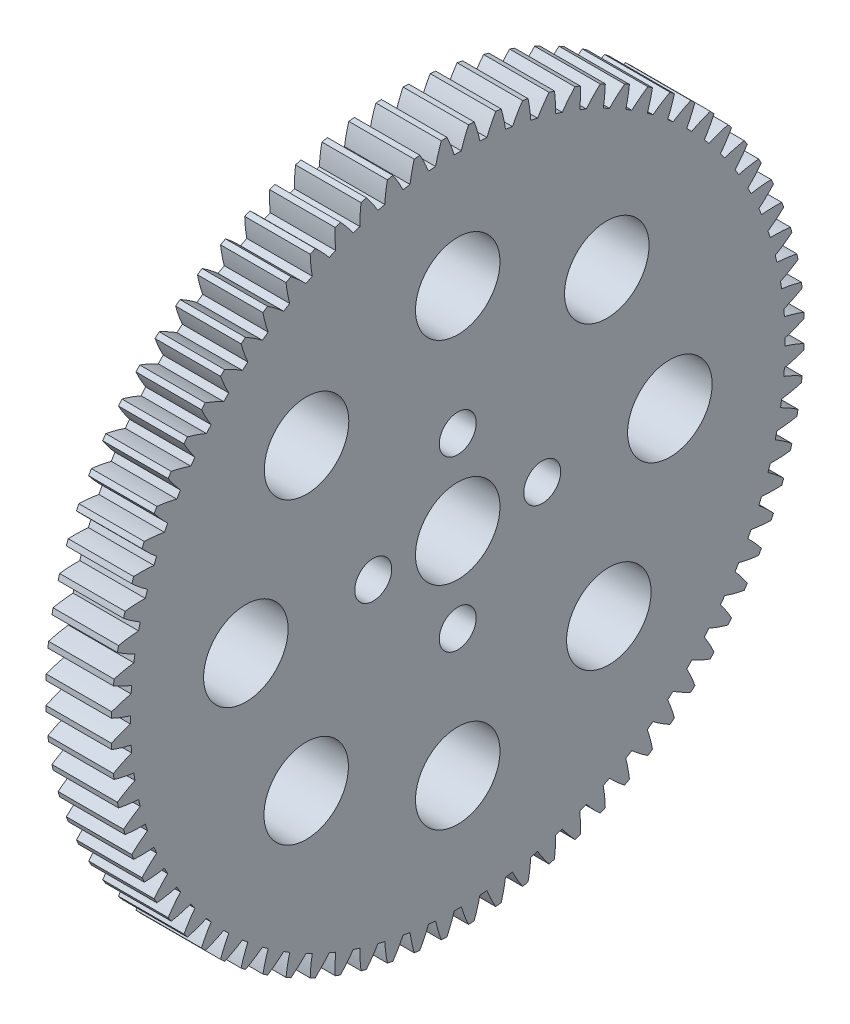
from build123d import *

# Parameters (mm, degrees)
SKETCH1_R           = 4
SKETCH1_R_2         = 1.75
BOSS_EXTRUDE1_DEPTH = 6.2


with BuildPart() as part:
    # Sketch1 → Boss-Extrude1 (new body)
    with BuildSketch(Plane(origin=(0, 0, 0), x_dir=(0, -1, 0), z_dir=(-1, 0, 0))):
        with BuildLine():
            ThreePointArc((-32.540485036, -4.117867604), (-31.611759802, -4.35271874), (-30.668071435, -4.517454533))
            ThreePointArc((-30.668071435, -4.517454533), (-30.61735087, -4.849311982), (-30.563039402, -5.180600688))
            ThreePointArc((-30.563039402, -5.180600688), (-31.409634214, -5.62888948), (-32.220331407, -6.139238063))
            ThreePointArc((-32.220331407, -6.139238063), (-32.169757197, -6.398962562), (-32.117089412, -6.658270623))
            ThreePointArc((-32.117089412, -6.658270623), (-31.17280092, -6.819530849), (-30.219096608, -6.909717881))
            ThreePointArc((-30.219096608, -6.909717881), (-30.142495162, -7.236572834), (-30.062358507, -7.562579059))
            ThreePointArc((-30.062358507, -7.562579059), (-30.871171216, -8.075908989), (-31.639327812, -8.648290907))
            ThreePointArc((-31.639327812, -8.648290907), (-31.568531756, -8.903246756), (-31.495681252, -9.15762319))
            ThreePointArc((-31.495681252, -9.15762319), (-30.541651355, -9.244298283), (-29.583811002, -9.25938052))
            ThreePointArc((-29.583811002, -9.25938052), (-29.481800949, -9.579217809), (-29.376333174, -9.897931615))
            ThreePointArc((-29.376333174, -9.897931615), (-30.142377181, -10.473137835), (-30.863257239, -11.104024162))
            ThreePointArc((-30.863257239, -11.104024162), (-30.772675818, -11.352639472), (-30.680091743, -11.600515964))
            ThreePointArc((-30.680091743, -11.600515964), (-29.722202353, -11.612071544), (-28.766131363, -11.551955999))
            ThreePointArc((-28.766131363, -11.551955999), (-28.639341628, -11.86280372), (-28.509192978, -12.172260132))
            ThreePointArc((-28.509192978, -12.172260132), (-29.227745368, -12.805796303), (-29.896904422, -13.491297415))
            ThreePointArc((-29.896904422, -13.491297415), (-29.787096101, -13.732039391), (-29.675349267, -13.9718877))
            ThreePointArc((-29.675349267, -13.9718877), (-28.719506089, -13.908252522), (-27.771098959, -13.773309829))
            ThreePointArc((-27.771098959, -13.773309829), (-27.620311243, -14.073251501), (-27.466284128, -14.371542617))
            ThreePointArc((-27.466284128, -14.371542617), (-28.132914785, -15.059502778), (-28.746227248, -15.795392334))
            ThreePointArc((-28.746227248, -15.795392334), (-28.617869032, -16.026776721), (-28.487648394, -16.257118102))
            ThreePointArc((-28.487648394, -16.257118102), (-27.53974452, -16.118684499), (-26.604848494, -15.909746623))
            ThreePointArc((-26.604848494, -15.909746623), (-26.430992455, -16.196933008), (-26.254036502, -16.482219763))
            ThreePointArc((-26.254036502, -16.482219763), (-26.864635428, -17.220362411), (-27.418320024, -18.002103406))
            ThreePointArc((-27.418320024, -18.002103406), (-27.272203284, -18.222703643), (-27.124311696, -18.442117965))
            ThreePointArc((-27.124311696, -18.442117965), (-26.190191269, -18.229739426), (-25.274570292, -17.948094538))
            ThreePointArc((-25.274570292, -17.948094538), (-25.078717809, -18.220755036), (-24.879924011, -18.491278544))
            ThreePointArc((-24.879924011, -18.491278544), (-25.430726659, -19.275052784), (-25.921369739, -20.097825525))
            ThreePointArc((-25.921369739, -20.097825525), (-25.758395333, -20.306281537), (-25.593744596, -20.513416038))
            ThreePointArc((-25.593744596, -20.513416038), (-24.679166779, -20.228401947), (-23.788465959, -19.875786483))
            ThreePointArc((-23.788465959, -19.875786483), (-23.571824528, -20.13224005), (-23.352418516, -20.386332443))
            ThreePointArc((-23.352418516, -20.386332443), (-23.840029005, -21.210906046), (-24.26460559, -22.069637866))
            ThreePointArc((-24.26460559, -22.069637866), (-24.085778309, -22.264664453), (-23.905383551, -22.458242079))
            ThreePointArc((-23.905383551, -22.458242079), (-23.015987019, -22.102349643), (-22.155697823, -21.680937594))
            ThreePointArc((-22.155697823, -21.680937594), (-21.91960311, -21.91960311), (-21.680937594, -22.155697823))
            ThreePointArc((-21.680937594, -22.155697823), (-22.102349643, -23.015987019), (-22.458242079, -23.905383551))
            ThreePointArc((-22.458242079, -23.905383551), (-22.264664453, -24.085778309), (-22.069637866, -24.26460559))
            ThreePointArc((-22.069637866, -24.26460559), (-21.210906046, -23.840029005), (-20.386332443, -23.352418516))
            ThreePointArc((-20.386332443, -23.352418516), (-20.13224005, -23.571824528), (-19.875786483, -23.788465959))
            ThreePointArc((-19.875786483, -23.788465959), (-20.228401947, -24.679166779), (-20.513416038, -25.593744596))
            ThreePointArc((-20.513416038, -25.593744596), (-20.306281537, -25.758395333), (-20.097825525, -25.921369739))
            ThreePointArc((-20.097825525, -25.921369739), (-19.275052784, -25.430726659), (-18.491278544, -24.879924011))
            ThreePointArc((-18.491278544, -24.879924011), (-18.220755036, -25.078717809), (-17.948094538, -25.274570292))
            ThreePointArc((-17.948094538, -25.274570292), (-18.229739426, -26.190191269), (-18.442117965, -27.124311696))
            ThreePointArc((-18.442117965, -27.124311696), (-18.222703643, -27.272203284), (-18.002103406, -27.418320024))
            ThreePointArc((-18.002103406, -27.418320024), (-17.220362411, -26.864635428), (-16.482219763, -26.254036502))
            ThreePointArc((-16.482219763, -26.254036502), (-16.196933008, -26.430992455), (-15.909746623, -26.604848494))
            ThreePointArc((-15.909746623, -26.604848494), (-16.118684499, -27.53974452), (-16.257118102, -28.487648394))
            ThreePointArc((-16.257118102, -28.487648394), (-16.026776721, -28.617869032), (-15.795392334, -28.746227248))
            ThreePointArc((-15.795392334, -28.746227248), (-15.059502778, -28.132914785), (-14.371542617, -27.466284128))
            ThreePointArc((-14.371542617, -27.466284128), (-14.073251501, -27.620311243), (-13.773309829, -27.771098959))
            ThreePointArc((-13.773309829, -27.771098959), (-13.908252522, -28.719506089), (-13.9718877, -29.675349267))
            ThreePointArc((-13.9718877, -29.675349267), (-13.732039391, -29.787096101), (-13.491297415, -29.896904422))
            ThreePointArc((-13.491297415, -29.896904422), (-12.805796303, -29.227745368), (-12.172260132, -28.509192978))
            ThreePointArc((-12.172260132, -28.509192978), (-11.86280372, -28.639341628), (-11.551955999, -28.766131363))
            ThreePointArc((-11.551955999, -28.766131363), (-11.612071544, -29.722202353), (-11.600515964, -30.680091743))
            ThreePointArc((-11.600515964, -30.680091743), (-11.352639472, -30.772675818), (-11.104024162, -30.863257239))
            ThreePointArc((-11.104024162, -30.863257239), (-10.473137835, -30.142377181), (-9.897931615, -29.376333174))
            ThreePointArc((-9.897931615, -29.376333174), (-9.579217809, -29.481800949), (-9.25938052, -29.583811002))
            ThreePointArc((-9.25938052, -29.583811002), (-9.244298283, -30.541651355), (-9.15762319, -31.495681252))
            ThreePointArc((-9.15762319, -31.495681252), (-8.903246756, -31.568531756), (-8.648290907, -31.639327812))
            ThreePointArc((-8.648290907, -31.639327812), (-8.075908989, -30.871171216), (-7.562579059, -30.062358507))
            ThreePointArc((-7.562579059, -30.062358507), (-7.236572834, -30.142495162), (-6.909717881, -30.219096608))
            ThreePointArc((-6.909717881, -30.219096608), (-6.819530849, -31.17280092), (-6.658270623, -32.117089412))
            ThreePointArc((-6.658270623, -32.117089412), (-6.398962562, -32.169757197), (-6.139238063, -32.220331407))
            ThreePointArc((-6.139238063, -32.220331407), (-5.62888948, -31.409634214), (-5.180600688, -30.563039402))
            ThreePointArc((-5.180600688, -30.563039402), (-4.849311982, -30.61735087), (-4.517454533, -30.668071435))
            ThreePointArc((-4.517454533, -30.668071435), (-4.35271874, -31.611759802), (-4.117867604, -32.540485036))
            ThreePointArc((-4.117867604, -32.540485036), (-3.855226637, -32.572645388), (-3.592334775, -32.602685946))
            ThreePointArc((-3.592334775, -32.602685946), (-3.147165994, -31.754446373), (-2.76668219, -30.875288997))
            ThreePointArc((-2.76668219, -30.875288997), (-2.432153508, -30.903440428), (-2.097339576, -30.927967403))
            ThreePointArc((-2.097339576, -30.927967403), (-1.859070673, -31.855821673), (-1.552076562, -32.763257749))
            ThreePointArc((-1.552076562, -32.763257749), (-1.287721957, -32.774712389), (-1.023283548, -32.784034083))
            ThreePointArc((-1.023283548, -32.784034083), (-0.646039184, -31.90348181), (-0.335706178, -30.997182168))
            ThreePointArc((-0.335706178, -30.997182168), (0, -30.999), (0.335706178, -30.997182168))
            ThreePointArc((0.335706178, -30.997182168), (0.646039184, -31.90348181), (1.023283548, -32.784034083))
            ThreePointArc((1.023283548, -32.784034083), (1.287721957, -32.774712389), (1.552076562, -32.763257749))
            ThreePointArc((1.552076562, -32.763257749), (1.859070673, -31.855821673), (2.097339576, -30.927967403))
            ThreePointArc((2.097339576, -30.927967403), (2.432153508, -30.903440428), (2.76668219, -30.875288997))
            ThreePointArc((2.76668219, -30.875288997), (3.147165994, -31.754446373), (3.592334775, -32.602685946))
            ThreePointArc((3.592334775, -32.602685946), (3.855226637, -32.572645388), (4.117867604, -32.540485036))
            ThreePointArc((4.117867604, -32.540485036), (4.35271874, -31.611759802), (4.517454533, -30.668071435))
            ThreePointArc((4.517454533, -30.668071435), (4.849311982, -30.61735087), (5.180600688, -30.563039402))
            ThreePointArc((5.180600688, -30.563039402), (5.62888948, -31.409634214), (6.139238063, -32.220331407))
            ThreePointArc((6.139238063, -32.220331407), (6.398962562, -32.169757197), (6.658270623, -32.117089412))
            ThreePointArc((6.658270623, -32.117089412), (6.819530849, -31.17280092), (6.909717881, -30.219096608))
            ThreePointArc((6.909717881, -30.219096608), (7.236572834, -30.142495162), (7.562579059, -30.062358507))
            ThreePointArc((7.562579059, -30.062358507), (8.075908989, -30.871171216), (8.648290907, -31.639327812))
            ThreePointArc((8.648290907, -31.639327812), (8.903246756, -31.568531756), (9.15762319, -31.495681252))
            ThreePointArc((9.15762319, -31.495681252), (9.244298283, -30.541651355), (9.25938052, -29.583811002))
            ThreePointArc((9.25938052, -29.583811002), (9.579217809, -29.481800949), (9.897931615, -29.376333174))
            ThreePointArc((9.897931615, -29.376333174), (10.473137835, -30.142377181), (11.104024162, -30.863257239))
            ThreePointArc((11.104024162, -30.863257239), (11.352639472, -30.772675818), (11.600515964, -30.680091743))
            ThreePointArc((11.600515964, -30.680091743), (11.612071544, -29.722202353), (11.551955999, -28.766131363))
            ThreePointArc((11.551955999, -28.766131363), (11.86280372, -28.639341628), (12.172260132, -28.509192978))
            ThreePointArc((12.172260132, -28.509192978), (12.805796303, -29.227745368), (13.491297415, -29.896904422))
            ThreePointArc((13.491297415, -29.896904422), (13.732039391, -29.787096101), (13.9718877, -29.675349267))
            ThreePointArc((13.9718877, -29.675349267), (13.908252522, -28.719506089), (13.773309829, -27.771098959))
            ThreePointArc((13.773309829, -27.771098959), (14.073251501, -27.620311243), (14.371542617, -27.466284128))
            ThreePointArc((14.371542617, -27.466284128), (15.059502778, -28.132914785), (15.795392334, -28.746227248))
            ThreePointArc((15.795392334, -28.746227248), (16.026776721, -28.617869032), (16.257118102, -28.487648394))
            ThreePointArc((16.257118102, -28.487648394), (16.118684499, -27.53974452), (15.909746623, -26.604848494))
            ThreePointArc((15.909746623, -26.604848494), (16.196933008, -26.430992455), (16.482219763, -26.254036502))
            ThreePointArc((16.482219763, -26.254036502), (17.220362411, -26.864635428), (18.002103406, -27.418320024))
            ThreePointArc((18.002103406, -27.418320024), (18.222703643, -27.272203284), (18.442117965, -27.124311696))
            ThreePointArc((18.442117965, -27.124311696), (18.229739426, -26.190191269), (17.948094538, -25.274570292))
            ThreePointArc((17.948094538, -25.274570292), (18.220755036, -25.078717809), (18.491278544, -24.879924011))
            ThreePointArc((18.491278544, -24.879924011), (19.275052784, -25.430726659), (20.097825525, -25.921369739))
            ThreePointArc((20.097825525, -25.921369739), (20.306281537, -25.758395333), (20.513416038, -25.593744596))
            ThreePointArc((20.513416038, -25.593744596), (20.228401947, -24.679166779), (19.875786483, -23.788465959))
            ThreePointArc((19.875786483, -23.788465959), (20.13224005, -23.571824528), (20.386332443, -23.352418516))
            ThreePointArc((20.386332443, -23.352418516), (21.210906046, -23.840029005), (22.069637866, -24.26460559))
            ThreePointArc((22.069637866, -24.26460559), (22.264664453, -24.085778309), (22.458242079, -23.905383551))
            ThreePointArc((22.458242079, -23.905383551), (22.102349643, -23.015987019), (21.680937594, -22.155697823))
            ThreePointArc((21.680937594, -22.155697823), (21.91960311, -21.91960311), (22.155697823, -21.680937594))
            ThreePointArc((22.155697823, -21.680937594), (23.015987019, -22.102349643), (23.905383551, -22.458242079))
            ThreePointArc((23.905383551, -22.458242079), (24.085778309, -22.264664453), (24.26460559, -22.069637866))
            ThreePointArc((24.26460559, -22.069637866), (23.840029005, -21.210906046), (23.352418516, -20.386332443))
            ThreePointArc((23.352418516, -20.386332443), (23.571824528, -20.13224005), (23.788465959, -19.875786483))
            ThreePointArc((23.788465959, -19.875786483), (24.679166779, -20.228401947), (25.593744596, -20.513416038))
            ThreePointArc((25.593744596, -20.513416038), (25.758395333, -20.306281537), (25.921369739, -20.097825525))
            ThreePointArc((25.921369739, -20.097825525), (25.430726659, -19.275052784), (24.879924011, -18.491278544))
            ThreePointArc((24.879924011, -18.491278544), (25.078717809, -18.220755036), (25.274570292, -17.948094538))
            ThreePointArc((25.274570292, -17.948094538), (26.190191269, -18.229739426), (27.124311696, -18.442117965))
            ThreePointArc((27.124311696, -18.442117965), (27.272203284, -18.222703643), (27.418320024, -18.002103406))
            ThreePointArc((27.418320024, -18.002103406), (26.864635428, -17.220362411), (26.254036502, -16.482219763))
            ThreePointArc((26.254036502, -16.482219763), (26.430992455, -16.196933008), (26.604848494, -15.909746623))
            ThreePointArc((26.604848494, -15.909746623), (27.53974452, -16.118684499), (28.487648394, -16.257118102))
            ThreePointArc((28.487648394, -16.257118102), (28.617869032, -16.026776721), (28.746227248, -15.795392334))
            ThreePointArc((28.746227248, -15.795392334), (28.132914785, -15.059502778), (27.466284128, -14.371542617))
            ThreePointArc((27.466284128, -14.371542617), (27.620311243, -14.073251501), (27.771098959, -13.773309829))
            ThreePointArc((27.771098959, -13.773309829), (28.719506089, -13.908252522), (29.675349267, -13.9718877))
            ThreePointArc((29.675349267, -13.9718877), (29.787096101, -13.732039391), (29.896904422, -13.491297415))
            ThreePointArc((29.896904422, -13.491297415), (29.227745368, -12.805796303), (28.509192978, -12.172260132))
            ThreePointArc((28.509192978, -12.172260132), (28.639341628, -11.86280372), (28.766131363, -11.551955999))
            ThreePointArc((28.766131363, -11.551955999), (29.722202353, -11.612071544), (30.680091743, -11.600515964))
            ThreePointArc((30.680091743, -11.600515964), (30.772675818, -11.352639472), (30.863257239, -11.104024162))
            ThreePointArc((30.863257239, -11.104024162), (30.142377181, -10.473137835), (29.376333174, -9.897931615))
            ThreePointArc((29.376333174, -9.897931615), (29.481800949, -9.579217809), (29.583811002, -9.25938052))
            ThreePointArc((29.583811002, -9.25938052), (30.541651355, -9.244298283), (31.495681252, -9.15762319))
            ThreePointArc((31.495681252, -9.15762319), (31.568531756, -8.903246756), (31.639327812, -8.648290907))
            ThreePointArc((31.639327812, -8.648290907), (30.871171216, -8.075908989), (30.062358507, -7.562579059))
            ThreePointArc((30.062358507, -7.562579059), (30.142495162, -7.236572834), (30.219096608, -6.909717881))
            ThreePointArc((30.219096608, -6.909717881), (31.17280092, -6.819530849), (32.117089412, -6.658270623))
            ThreePointArc((32.117089412, -6.658270623), (32.169757197, -6.398962562), (32.220331407, -6.139238063))
            ThreePointArc((32.220331407, -6.139238063), (31.409634214, -5.62888948), (30.563039402, -5.180600688))
            ThreePointArc((30.563039402, -5.180600688), (30.61735087, -4.849311982), (30.668071435, -4.517454533))
            ThreePointArc((30.668071435, -4.517454533), (31.611759802, -4.35271874), (32.540485036, -4.117867604))
            ThreePointArc((32.540485036, -4.117867604), (32.572645388, -3.855226637), (32.602685946, -3.592334775))
            ThreePointArc((32.602685946, -3.592334775), (31.754446373, -3.147165994), (30.875288997, -2.76668219))
            ThreePointArc((30.875288997, -2.76668219), (30.903440428, -2.432153508), (30.927967403, -2.097339576))
            ThreePointArc((30.927967403, -2.097339576), (31.855821673, -1.859070673), (32.763257749, -1.552076562))
            ThreePointArc((32.763257749, -1.552076562), (32.774712389, -1.287721957), (32.784034083, -1.023283548))
            ThreePointArc((32.784034083, -1.023283548), (31.90348181, -0.646039184), (30.997182168, -0.335706178))
            ThreePointArc((30.997182168, -0.335706178), (30.999, 0), (30.997182168, 0.335706178))
            ThreePointArc((30.997182168, 0.335706178), (31.90348181, 0.646039184), (32.784034083, 1.023283548))
            ThreePointArc((32.784034083, 1.023283548), (32.774712389, 1.287721957), (32.763257749, 1.552076562))
            ThreePointArc((32.763257749, 1.552076562), (31.855821673, 1.859070673), (30.927967403, 2.097339576))
            ThreePointArc((30.927967403, 2.097339576), (30.903440428, 2.432153508), (30.875288997, 2.76668219))
            ThreePointArc((30.875288997, 2.76668219), (31.754446373, 3.147165994), (32.602685946, 3.592334775))
            ThreePointArc((32.602685946, 3.592334775), (32.572645388, 3.855226637), (32.540485036, 4.117867604))
            ThreePointArc((32.540485036, 4.117867604), (31.611759802, 4.35271874), (30.668071435, 4.517454533))
            ThreePointArc((30.668071435, 4.517454533), (30.61735087, 4.849311982), (30.563039402, 5.180600688))
            ThreePointArc((30.563039402, 5.180600688), (31.409634214, 5.62888948), (32.220331407, 6.139238063))
            ThreePointArc((32.220331407, 6.139238063), (32.169757197, 6.398962562), (32.117089412, 6.658270623))
            ThreePointArc((32.117089412, 6.658270623), (31.17280092, 6.819530849), (30.219096608, 6.909717881))
            ThreePointArc((30.219096608, 6.909717881), (30.142495162, 7.236572834), (30.062358507, 7.562579059))
            ThreePointArc((30.062358507, 7.562579059), (30.871171216, 8.075908989), (31.639327812, 8.648290907))
            ThreePointArc((31.639327812, 8.648290907), (31.568531756, 8.903246756), (31.495681252, 9.15762319))
            ThreePointArc((31.495681252, 9.15762319), (30.541651355, 9.244298283), (29.583811002, 9.25938052))
            ThreePointArc((29.583811002, 9.25938052), (29.481800949, 9.579217809), (29.376333174, 9.897931615))
            ThreePointArc((29.376333174, 9.897931615), (30.142377181, 10.473137835), (30.863257239, 11.104024162))
            ThreePointArc((30.863257239, 11.104024162), (30.772675818, 11.352639472), (30.680091743, 11.600515964))
            ThreePointArc((30.680091743, 11.600515964), (29.722202353, 11.612071544), (28.766131363, 11.551955999))
            ThreePointArc((28.766131363, 11.551955999), (28.639341628, 11.86280372), (28.509192978, 12.172260132))
            ThreePointArc((28.509192978, 12.172260132), (29.227745368, 12.805796303), (29.896904422, 13.491297415))
            ThreePointArc((29.896904422, 13.491297415), (29.787096101, 13.732039391), (29.675349267, 13.9718877))
            ThreePointArc((29.675349267, 13.9718877), (28.719506089, 13.908252522), (27.771098959, 13.773309829))
            ThreePointArc((27.771098959, 13.773309829), (27.620311243, 14.073251501), (27.466284128, 14.371542617))
            ThreePointArc((27.466284128, 14.371542617), (28.132914785, 15.059502778), (28.746227248, 15.795392334))
            ThreePointArc((28.746227248, 15.795392334), (28.617869032, 16.026776721), (28.487648394, 16.257118102))
            ThreePointArc((28.487648394, 16.257118102), (27.53974452, 16.118684499), (26.604848494, 15.909746623))
            ThreePointArc((26.604848494, 15.909746623), (26.430992455, 16.196933008), (26.254036502, 16.482219763))
            ThreePointArc((26.254036502, 16.482219763), (26.864635428, 17.220362411), (27.418320024, 18.002103406))
            ThreePointArc((27.418320024, 18.002103406), (27.272203284, 18.222703643), (27.124311696, 18.442117965))
            ThreePointArc((27.124311696, 18.442117965), (26.190191269, 18.229739426), (25.274570292, 17.948094538))
            ThreePointArc((25.274570292, 17.948094538), (25.078717809, 18.220755036), (24.879924011, 18.491278544))
            ThreePointArc((24.879924011, 18.491278544), (25.430726659, 19.275052784), (25.921369739, 20.097825525))
            ThreePointArc((25.921369739, 20.097825525), (25.758395333, 20.306281537), (25.593744596, 20.513416038))
            ThreePointArc((25.593744596, 20.513416038), (24.679166779, 20.228401947), (23.788465959, 19.875786483))
            ThreePointArc((23.788465959, 19.875786483), (23.571824528, 20.13224005), (23.352418516, 20.386332443))
            ThreePointArc((23.352418516, 20.386332443), (23.840029005, 21.210906046), (24.26460559, 22.069637866))
            ThreePointArc((24.26460559, 22.069637866), (24.085778309, 22.264664453), (23.905383551, 22.458242079))
            ThreePointArc((23.905383551, 22.458242079), (23.015987019, 22.102349643), (22.155697823, 21.680937594))
            ThreePointArc((22.155697823, 21.680937594), (21.91960311, 21.91960311), (21.680937594, 22.155697823))
            ThreePointArc((21.680937594, 22.155697823), (22.102349643, 23.015987019), (22.458242079, 23.905383551))
            ThreePointArc((22.458242079, 23.905383551), (22.264664453, 24.085778309), (22.069637866, 24.26460559))
            ThreePointArc((22.069637866, 24.26460559), (21.210906046, 23.840029005), (20.386332443, 23.352418516))
            ThreePointArc((20.386332443, 23.352418516), (20.13224005, 23.571824528), (19.875786483, 23.788465959))
            ThreePointArc((19.875786483, 23.788465959), (20.228401947, 24.679166779), (20.513416038, 25.593744596))
            ThreePointArc((20.513416038, 25.593744596), (20.306281537, 25.758395333), (20.097825525, 25.921369739))
            ThreePointArc((20.097825525, 25.921369739), (19.275052784, 25.430726659), (18.491278544, 24.879924011))
            ThreePointArc((18.491278544, 24.879924011), (18.220755036, 25.078717809), (17.948094538, 25.274570292))
            ThreePointArc((17.948094538, 25.274570292), (18.229739426, 26.190191269), (18.442117965, 27.124311696))
            ThreePointArc((18.442117965, 27.124311696), (18.222703643, 27.272203284), (18.002103406, 27.418320024))
            ThreePointArc((18.002103406, 27.418320024), (17.220362411, 26.864635428), (16.482219763, 26.254036502))
            ThreePointArc((16.482219763, 26.254036502), (16.196933008, 26.430992455), (15.909746623, 26.604848494))
            ThreePointArc((15.909746623, 26.604848494), (16.118684499, 27.53974452), (16.257118102, 28.487648394))
            ThreePointArc((16.257118102, 28.487648394), (16.026776721, 28.617869032), (15.795392334, 28.746227248))
            ThreePointArc((15.795392334, 28.746227248), (15.059502778, 28.132914785), (14.371542617, 27.466284128))
            ThreePointArc((14.371542617, 27.466284128), (14.073251501, 27.620311243), (13.773309829, 27.771098959))
            ThreePointArc((13.773309829, 27.771098959), (13.908252522, 28.719506089), (13.9718877, 29.675349267))
            ThreePointArc((13.9718877, 29.675349267), (13.732039391, 29.787096101), (13.491297415, 29.896904422))
            ThreePointArc((13.491297415, 29.896904422), (12.805796303, 29.227745368), (12.172260132, 28.509192978))
            ThreePointArc((12.172260132, 28.509192978), (11.86280372, 28.639341628), (11.551955999, 28.766131363))
            ThreePointArc((11.551955999, 28.766131363), (11.612071544, 29.722202353), (11.600515964, 30.680091743))
            ThreePointArc((11.600515964, 30.680091743), (11.352639472, 30.772675818), (11.104024162, 30.863257239))
            ThreePointArc((11.104024162, 30.863257239), (10.473137835, 30.142377181), (9.897931615, 29.376333174))
            ThreePointArc((9.897931615, 29.376333174), (9.579217809, 29.481800949), (9.25938052, 29.583811002))
            ThreePointArc((9.25938052, 29.583811002), (9.244298283, 30.541651355), (9.15762319, 31.495681252))
            ThreePointArc((9.15762319, 31.495681252), (8.903246756, 31.568531756), (8.648290907, 31.639327812))
            ThreePointArc((8.648290907, 31.639327812), (8.075908989, 30.871171216), (7.562579059, 30.062358507))
            ThreePointArc((7.562579059, 30.062358507), (7.236572834, 30.142495162), (6.909717881, 30.219096608))
            ThreePointArc((6.909717881, 30.219096608), (6.819530849, 31.17280092), (6.658270623, 32.117089412))
            ThreePointArc((6.658270623, 32.117089412), (6.398962562, 32.169757197), (6.139238063, 32.220331407))
            ThreePointArc((6.139238063, 32.220331407), (5.62888948, 31.409634214), (5.180600688, 30.563039402))
            ThreePointArc((5.180600688, 30.563039402), (4.849311982, 30.61735087), (4.517454533, 30.668071435))
            ThreePointArc((4.517454533, 30.668071435), (4.35271874, 31.611759802), (4.117867604, 32.540485036))
            ThreePointArc((4.117867604, 32.540485036), (3.855226637, 32.572645388), (3.592334775, 32.602685946))
            ThreePointArc((3.592334775, 32.602685946), (3.147165994, 31.754446373), (2.76668219, 30.875288997))
            ThreePointArc((2.76668219, 30.875288997), (2.432153508, 30.903440428), (2.097339576, 30.927967403))
            ThreePointArc((2.097339576, 30.927967403), (1.859070673, 31.855821673), (1.552076562, 32.763257749))
            ThreePointArc((1.552076562, 32.763257749), (1.287721957, 32.774712389), (1.023283548, 32.784034083))
            ThreePointArc((1.023283548, 32.784034083), (0.646039184, 31.90348181), (0.335706178, 30.997182168))
            ThreePointArc((0.335706178, 30.997182168), (0, 30.999), (-0.335706178, 30.997182168))
            ThreePointArc((-0.335706178, 30.997182168), (-0.646039184, 31.90348181), (-1.023283548, 32.784034083))
            ThreePointArc((-1.023283548, 32.784034083), (-1.287721957, 32.774712389), (-1.552076562, 32.763257749))
            ThreePointArc((-1.552076562, 32.763257749), (-1.859070673, 31.855821673), (-2.097339576, 30.927967403))
            ThreePointArc((-2.097339576, 30.927967403), (-2.432153508, 30.903440428), (-2.76668219, 30.875288997))
            ThreePointArc((-2.76668219, 30.875288997), (-3.147165994, 31.754446373), (-3.592334775, 32.602685946))
            ThreePointArc((-3.592334775, 32.602685946), (-3.855226637, 32.572645388), (-4.117867604, 32.540485036))
            ThreePointArc((-4.117867604, 32.540485036), (-4.35271874, 31.611759802), (-4.517454533, 30.668071435))
            ThreePointArc((-4.517454533, 30.668071435), (-4.849311982, 30.61735087), (-5.180600688, 30.563039402))
            ThreePointArc((-5.180600688, 30.563039402), (-5.62888948, 31.409634214), (-6.139238063, 32.220331407))
            ThreePointArc((-6.139238063, 32.220331407), (-6.398962562, 32.169757197), (-6.658270623, 32.117089412))
            ThreePointArc((-6.658270623, 32.117089412), (-6.819530849, 31.17280092), (-6.909717881, 30.219096608))
            ThreePointArc((-6.909717881, 30.219096608), (-7.236572834, 30.142495162), (-7.562579059, 30.062358507))
            ThreePointArc((-7.562579059, 30.062358507), (-8.075908989, 30.871171216), (-8.648290907, 31.639327812))
            ThreePointArc((-8.648290907, 31.639327812), (-8.903246756, 31.568531756), (-9.15762319, 31.495681252))
            ThreePointArc((-9.15762319, 31.495681252), (-9.244298283, 30.541651355), (-9.25938052, 29.583811002))
            ThreePointArc((-9.25938052, 29.583811002), (-9.579217809, 29.481800949), (-9.897931615, 29.376333174))
            ThreePointArc((-9.897931615, 29.376333174), (-10.473137835, 30.142377181), (-11.104024162, 30.863257239))
            ThreePointArc((-11.104024162, 30.863257239), (-11.352639472, 30.772675818), (-11.600515964, 30.680091743))
            ThreePointArc((-11.600515964, 30.680091743), (-11.612071544, 29.722202353), (-11.551955999, 28.766131363))
            ThreePointArc((-11.551955999, 28.766131363), (-11.86280372, 28.639341628), (-12.172260132, 28.509192978))
            ThreePointArc((-12.172260132, 28.509192978), (-12.805796303, 29.227745368), (-13.491297415, 29.896904422))
            ThreePointArc((-13.491297415, 29.896904422), (-13.732039391, 29.787096101), (-13.9718877, 29.675349267))
            ThreePointArc((-13.9718877, 29.675349267), (-13.908252522, 28.719506089), (-13.773309829, 27.771098959))
            ThreePointArc((-13.773309829, 27.771098959), (-14.073251501, 27.620311243), (-14.371542617, 27.466284128))
            ThreePointArc((-14.371542617, 27.466284128), (-15.059502778, 28.132914785), (-15.795392334, 28.746227248))
            ThreePointArc((-15.795392334, 28.746227248), (-16.026776721, 28.617869032), (-16.257118102, 28.487648394))
            ThreePointArc((-16.257118102, 28.487648394), (-16.118684499, 27.53974452), (-15.909746623, 26.604848494))
            ThreePointArc((-15.909746623, 26.604848494), (-16.196933008, 26.430992455), (-16.482219763, 26.254036502))
            ThreePointArc((-16.482219763, 26.254036502), (-17.220362411, 26.864635428), (-18.002103406, 27.418320024))
            ThreePointArc((-18.002103406, 27.418320024), (-18.222703643, 27.272203284), (-18.442117965, 27.124311696))
            ThreePointArc((-18.442117965, 27.124311696), (-18.229739426, 26.190191269), (-17.948094538, 25.274570292))
            ThreePointArc((-17.948094538, 25.274570292), (-18.220755036, 25.078717809), (-18.491278544, 24.879924011))
            ThreePointArc((-18.491278544, 24.879924011), (-19.275052784, 25.430726659), (-20.097825525, 25.921369739))
            ThreePointArc((-20.097825525, 25.921369739), (-20.306281537, 25.758395333), (-20.513416038, 25.593744596))
            ThreePointArc((-20.513416038, 25.593744596), (-20.228401947, 24.679166779), (-19.875786483, 23.788465959))
            ThreePointArc((-19.875786483, 23.788465959), (-20.13224005, 23.571824528), (-20.386332443, 23.352418516))
            ThreePointArc((-20.386332443, 23.352418516), (-21.210906046, 23.840029005), (-22.069637866, 24.26460559))
            ThreePointArc((-22.069637866, 24.26460559), (-22.264664453, 24.085778309), (-22.458242079, 23.905383551))
            ThreePointArc((-22.458242079, 23.905383551), (-22.102349643, 23.015987019), (-21.680937594, 22.155697823))
            ThreePointArc((-21.680937594, 22.155697823), (-21.91960311, 21.91960311), (-22.155697823, 21.680937594))
            ThreePointArc((-22.155697823, 21.680937594), (-23.015987019, 22.102349643), (-23.905383551, 22.458242079))
            ThreePointArc((-23.905383551, 22.458242079), (-24.085778309, 22.264664453), (-24.26460559, 22.069637866))
            ThreePointArc((-24.26460559, 22.069637866), (-23.840029005, 21.210906046), (-23.352418516, 20.386332443))
            ThreePointArc((-23.352418516, 20.386332443), (-23.571824528, 20.13224005), (-23.788465959, 19.875786483))
            ThreePointArc((-23.788465959, 19.875786483), (-24.679166779, 20.228401947), (-25.593744596, 20.513416038))
            ThreePointArc((-25.593744596, 20.513416038), (-25.758395333, 20.306281537), (-25.921369739, 20.097825525))
            ThreePointArc((-25.921369739, 20.097825525), (-25.430726659, 19.275052784), (-24.879924011, 18.491278544))
            ThreePointArc((-24.879924011, 18.491278544), (-25.078717809, 18.220755036), (-25.274570292, 17.948094538))
            ThreePointArc((-25.274570292, 17.948094538), (-26.190191269, 18.229739426), (-27.124311696, 18.442117965))
            ThreePointArc((-27.124311696, 18.442117965), (-27.272203284, 18.222703643), (-27.418320024, 18.002103406))
            ThreePointArc((-27.418320024, 18.002103406), (-26.864635428, 17.220362411), (-26.254036502, 16.482219763))
            ThreePointArc((-26.254036502, 16.482219763), (-26.430992455, 16.196933008), (-26.604848494, 15.909746623))
            ThreePointArc((-26.604848494, 15.909746623), (-27.53974452, 16.118684499), (-28.487648394, 16.257118102))
            ThreePointArc((-28.487648394, 16.257118102), (-28.617869032, 16.026776721), (-28.746227248, 15.795392334))
            ThreePointArc((-28.746227248, 15.795392334), (-28.132914785, 15.059502778), (-27.466284128, 14.371542617))
            ThreePointArc((-27.466284128, 14.371542617), (-27.620311243, 14.073251501), (-27.771098959, 13.773309829))
            ThreePointArc((-27.771098959, 13.773309829), (-28.719506089, 13.908252522), (-29.675349267, 13.9718877))
            ThreePointArc((-29.675349267, 13.9718877), (-29.787096101, 13.732039391), (-29.896904422, 13.491297415))
            ThreePointArc((-29.896904422, 13.491297415), (-29.227745368, 12.805796303), (-28.509192978, 12.172260132))
            ThreePointArc((-28.509192978, 12.172260132), (-28.639341628, 11.86280372), (-28.766131363, 11.551955999))
            ThreePointArc((-28.766131363, 11.551955999), (-29.722202353, 11.612071544), (-30.680091743, 11.600515964))
            ThreePointArc((-30.680091743, 11.600515964), (-30.772675818, 11.352639472), (-30.863257239, 11.104024162))
            ThreePointArc((-30.863257239, 11.104024162), (-30.142377181, 10.473137835), (-29.376333174, 9.897931615))
            ThreePointArc((-29.376333174, 9.897931615), (-29.481800949, 9.579217809), (-29.583811002, 9.25938052))
            ThreePointArc((-29.583811002, 9.25938052), (-30.541651355, 9.244298283), (-31.495681252, 9.15762319))
            ThreePointArc((-31.495681252, 9.15762319), (-31.568531756, 8.903246756), (-31.639327812, 8.648290907))
            ThreePointArc((-31.639327812, 8.648290907), (-30.871171216, 8.075908989), (-30.062358507, 7.562579059))
            ThreePointArc((-30.062358507, 7.562579059), (-30.142495162, 7.236572834), (-30.219096608, 6.909717881))
            ThreePointArc((-30.219096608, 6.909717881), (-31.17280092, 6.819530849), (-32.117089412, 6.658270623))
            ThreePointArc((-32.117089412, 6.658270623), (-32.169757197, 6.398962562), (-32.220331407, 6.139238063))
            ThreePointArc((-32.220331407, 6.139238063), (-31.409634214, 5.62888948), (-30.563039402, 5.180600688))
            ThreePointArc((-30.563039402, 5.180600688), (-30.61735087, 4.849311982), (-30.668071435, 4.517454533))
            ThreePointArc((-30.668071435, 4.517454533), (-31.611759802, 4.35271874), (-32.540485036, 4.117867604))
            ThreePointArc((-32.540485036, 4.117867604), (-32.572645388, 3.855226637), (-32.602685946, 3.592334775))
            ThreePointArc((-32.602685946, 3.592334775), (-31.754446373, 3.147165994), (-30.875288997, 2.76668219))
            ThreePointArc((-30.875288997, 2.76668219), (-30.903440428, 2.432153508), (-30.927967403, 2.097339576))
            ThreePointArc((-30.927967403, 2.097339576), (-31.855821673, 1.859070673), (-32.763257749, 1.552076562))
            ThreePointArc((-32.763257749, 1.552076562), (-32.774712389, 1.287721957), (-32.784034083, 1.023283548))
            ThreePointArc((-32.784034083, 1.023283548), (-31.90348181, 0.646039184), (-30.997182168, 0.335706178))
            ThreePointArc((-30.997182168, 0.335706178), (-30.999, 0), (-30.997182168, -0.335706178))
            ThreePointArc((-30.997182168, -0.335706178), (-31.90348181, -0.646039184), (-32.784034083, -1.023283548))
            ThreePointArc((-32.784034083, -1.023283548), (-32.774712389, -1.287721957), (-32.763257749, -1.552076562))
            ThreePointArc((-32.763257749, -1.552076562), (-31.855821673, -1.859070673), (-30.927967403, -2.097339576))
            ThreePointArc((-30.927967403, -2.097339576), (-30.903440428, -2.432153508), (-30.875288997, -2.76668219))
            ThreePointArc((-30.875288997, -2.76668219), (-31.754446373, -3.147165994), (-32.602685946, -3.592334775))
            ThreePointArc((-32.602685946, -3.592334775), (-32.572645388, -3.855226637), (-32.540485036, -4.117867604))
        make_face()
        Circle(SKETCH1_R, mode=Mode.SUBTRACT)
        with Locations((0, 8)):
            Circle(SKETCH1_R_2, mode=Mode.SUBTRACT)
        with Locations((-20.084034083, 0)):
            Circle(SKETCH1_R, mode=Mode.SUBTRACT)
        with Locations((20.063257749, 0)):
            Circle(SKETCH1_R, mode=Mode.SUBTRACT)
        with Locations((0, -20.084034083)):
            Circle(SKETCH1_R, mode=Mode.SUBTRACT)
        with Locations((0, 20.063257749)):
            Circle(SKETCH1_R, mode=Mode.SUBTRACT)
        with Locations((-14.36634376, -14.112602443)):
            Circle(SKETCH1_R, mode=Mode.SUBTRACT)
        with Locations((14.14202094, -14.306921905)):
            Circle(SKETCH1_R, mode=Mode.SUBTRACT)
        with Locations((14.135100494, 14.348299993)):
            Circle(SKETCH1_R, mode=Mode.SUBTRACT)
        with Locations((-14.159703758, 14.315040904)):
            Circle(SKETCH1_R, mode=Mode.SUBTRACT)
        with Locations((-8, 0)):
            Circle(SKETCH1_R_2, mode=Mode.SUBTRACT)
        with Locations((8, 0)):
            Circle(SKETCH1_R_2, mode=Mode.SUBTRACT)
        with Locations((0, -8)):
            Circle(SKETCH1_R_2, mode=Mode.SUBTRACT)
    extrude(amount=-BOSS_EXTRUDE1_DEPTH)


solid = part.part
